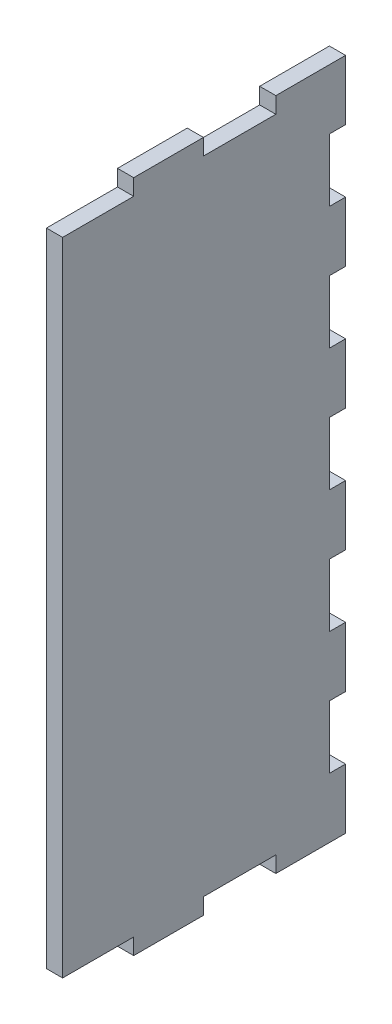
from build123d import *

# Parameters (mm, degrees)
BOSS_EXTRUDE1_DEPTH = 6


with BuildPart() as part:
    # Sketch1 → Boss-Extrude1 (new body)
    with BuildSketch(Plane(origin=(330, 0, 0), x_dir=(0, 0, -1), z_dir=(1, 0, 0))):
        Polygon((-52.75, 244), (-52.75, 250), (-78.625, 250), (-78.625, 244), (-105, 244), (-105, 6), (-78.625, 6), (-78.625, 0), (-52.75, 0), (-52.75, 6), (-25.875, 6), (-25.875, 0), (0, 0), (0, 22.272727273), (-6, 22.272727273), (-6, 45.545454545), (0, 45.545454545), (0, 67.818181818), (-6, 67.818181818), (-6, 91.090909091), (0, 91.090909091), (0, 113.363636364), (-6, 113.363636364), (-6, 136.636363636), (0, 136.636363636), (0, 158.909090909), (-6, 158.909090909), (-6, 182.181818182), (0, 182.181818182), (0, 204.454545455), (-6, 204.454545455), (-6, 227.727272727), (0, 227.727272727), (0, 250), (-25.875, 250), (-25.875, 244), align=None)
    extrude(amount=-BOSS_EXTRUDE1_DEPTH)


solid = part.part
